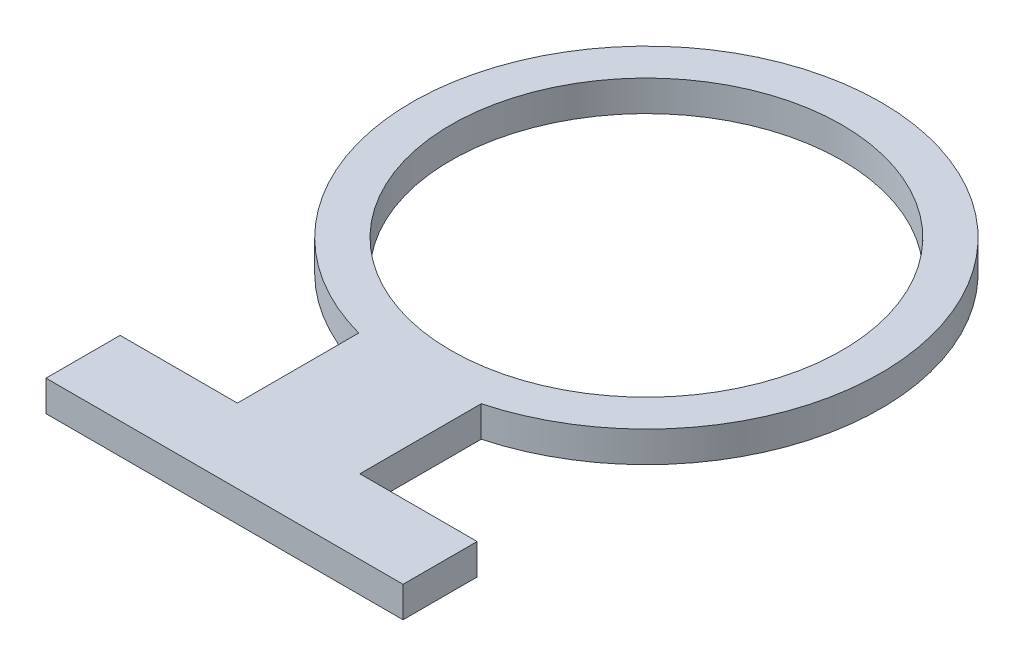
from build123d import *

# Parameters (mm, degrees)
SKETCH1_R           = 63.5
BOSS_EXTRUDE1_DEPTH = 10


with BuildPart() as part:
    # Sketch1 → Boss-Extrude1 (new body)
    with BuildSketch(Plane(origin=(0, 0, 0), x_dir=(1, 0, 0), z_dir=(0, 1, 0))):
        with BuildLine():
            ThreePointArc((19.89546001, -73.556853324), (0, 76.2), (-19.89546001, -73.556853324))
            Line((-19.89546001, -73.556853324), (-19.89546001, -112.983657034))
            Line((-19.89546001, -112.983657034), (-57.99546001, -112.983657034))
            Line((-57.99546001, -112.983657034), (-57.99546001, -137.056853324))
            Line((-57.99546001, -137.056853324), (57.99546001, -137.056853324))
            Line((57.99546001, -137.056853324), (57.99546001, -112.983657034))
            Line((57.99546001, -112.983657034), (19.89546001, -112.983657034))
            Line((19.89546001, -112.983657034), (19.89546001, -73.556853324))
        make_face()
        Circle(SKETCH1_R, mode=Mode.SUBTRACT)
    extrude(amount=BOSS_EXTRUDE1_DEPTH)


solid = part.part
